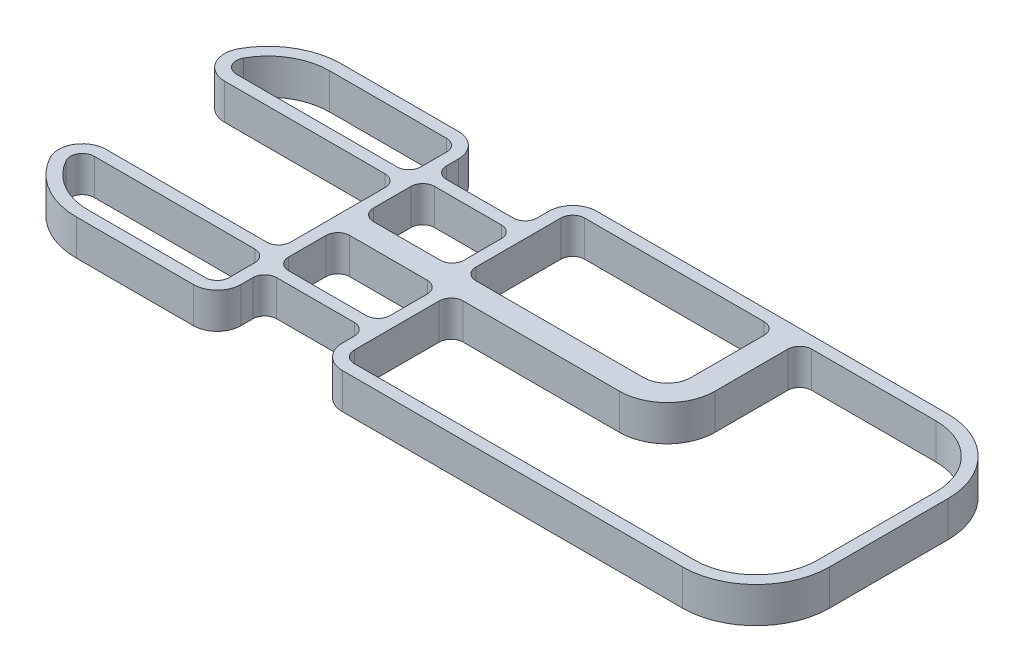
from build123d import *

# Parameters (mm, degrees)
BOSS_EXTRUDE1_DEPTH   = 19.05
BOSS_EXTRUDE1_2_DEPTH = 19.05
SKETCH4_W             = 6.35
SKETCH4_H             = 63.131908364
CUT_EXTRUDE4_DEPTH    = 19.05
BOSS_EXTRUDE2_DEPTH   = 19.05
BOSS_EXTRUDE3_DEPTH   = 19.05
FILLET2_R             = 6.35
FILLET3_R             = 12.7
FILLET4_R             = 12.7
FILLET5_R             = 25.4


with BuildPart() as part:
    # Sketch1 → Boss-Extrude1 (new body)
    with BuildSketch(Plane(origin=(0, 0, 0), x_dir=(1, 0, 0), z_dir=(0, 1, 0))):
        with BuildLine():
            Line((-200.920268311, 32.916976578), (-200.920268311, -30.214931786))
            ThreePointArc((-200.920268311, -30.214931786), (-189.456017676, -57.892081151), (-161.778868311, -69.356331786))
            Line((-161.778868311, -69.356331786), (-86.620268311, -69.356331786))
            Line((-86.620268311, -69.356331786), (-86.620268311, -63.006331786))
            Line((-86.620268311, -63.006331786), (-161.778868311, -63.006331786))
            ThreePointArc((-161.778868311, -63.006331786), (-184.965889616, -53.401953091), (-194.570268311, -30.214931786))
            Line((-194.570268311, -30.214931786), (-194.570268311, 32.916976578))
            ThreePointArc((-194.570268311, 32.916976578), (-184.965889616, 56.103997883), (-161.778868311, 65.708376578))
            Line((-161.778868311, 65.708376578), (-86.620268311, 65.708376578))
            Line((-86.620268311, 65.708376578), (-86.620268311, 72.058376578))
            Line((-86.620268311, 72.058376578), (-161.778868311, 72.058376578))
            ThreePointArc((-161.778868311, 72.058376578), (-189.456017676, 60.594125943), (-200.920268311, 32.916976578))
        make_face()
    extrude(amount=BOSS_EXTRUDE1_DEPTH)

    # Sketch4 → Cut-Extrude4 (cut)
    with BuildSketch(Plane(origin=(0, 19.05, 0), x_dir=(1, 0, 0), z_dir=(0, 1, 0))):
        with Locations((-197.745268311, 1.351022396)):
            Rectangle(SKETCH4_W, SKETCH4_H)
    extrude(amount=-CUT_EXTRUDE4_DEPTH, mode=Mode.SUBTRACT)

    # Sketch5 → Boss-Extrude2 (add)
    with BuildSketch(Plane(origin=(0, 0, 0), x_dir=(1, 0, 0), z_dir=(0, 1, 0))):
        with BuildLine():
            Line((-194.570268311, -30.214931786), (-86.620268311, -30.214931786))
            Line((-86.620268311, -30.214931786), (-86.620268311, -63.006331786))
            Line((-86.620268311, -63.006331786), (-92.970268311, -63.006331786))
            Line((-92.970268311, -63.006331786), (-92.970268311, -36.564931786))
            Line((-92.970268311, -36.564931786), (-193.949560159, -36.564931786))
            ThreePointArc((-193.949560159, -36.564931786), (-194.414722357, -33.405064174), (-194.570268311, -30.214931786))
        make_face()
        with BuildLine():
            Line((-92.970268311, 65.708376578), (-86.620268311, 65.708376578))
            Line((-86.620268311, 65.708376578), (-86.620268311, 32.916976578))
            Line((-86.620268311, 32.916976578), (-194.570268311, 32.916976578))
            ThreePointArc((-194.570268311, 32.916976578), (-194.414722357, 36.107108966), (-193.949560159, 39.266976578))
            Line((-193.949560159, 39.266976578), (-92.970268311, 39.266976578))
            Line((-92.970268311, 39.266976578), (-92.970268311, 65.708376578))
        make_face()
    extrude(amount=BOSS_EXTRUDE2_DEPTH)



with BuildPart() as body_2:
    # Sketch1 → Boss-Extrude1 2 (new body)
    with BuildSketch(Plane(origin=(0, 0, 0), x_dir=(1, 0, 0), z_dir=(0, 1, 0))):
        with BuildLine():
            Line((200.844440053, -30.214931786), (200.844440053, 32.916976578))
            ThreePointArc((200.844440053, 32.916976578), (189.380189418, 60.594125943), (161.703040053, 72.058376578))
            Line((161.703040053, 72.058376578), (-38.360268311, 72.058376578))
            Line((-38.360268311, 72.058376578), (-38.360268311, 65.708376578))
            Line((-38.360268311, 65.708376578), (161.703040053, 65.708376578))
            ThreePointArc((161.703040053, 65.708376578), (184.890061358, 56.103997883), (194.494440053, 32.916976578))
            Line((194.494440053, 32.916976578), (194.494440053, -30.214931786))
            ThreePointArc((194.494440053, -30.214931786), (184.890061358, -53.401953091), (161.703040053, -63.006331786))
            Line((161.703040053, -63.006331786), (-32.518268311, -63.006331786))
            Line((-32.518268311, -63.006331786), (-32.518268311, -69.356331786))
            Line((-32.518268311, -69.356331786), (161.703040053, -69.356331786))
            ThreePointArc((161.703040053, -69.356331786), (189.380189418, -57.892081151), (200.844440053, -30.214931786))
        make_face()
    extrude(amount=BOSS_EXTRUDE1_2_DEPTH)


with BuildPart() as part_1:
    add(part.part)

    add(body_2.part)  # Boss-Extrude3 merges body 2
    # Sketch6 → Boss-Extrude3 (add)
    with BuildSketch(Plane(origin=(0, 0, 0), x_dir=(1, 0, 0), z_dir=(0, 1, 0))):
        Polygon((-86.620268311, -43.956331786), (-32.518268311, -43.956331786), (-32.518268311, -63.006331786), (-26.168268311, -63.006331786), (-26.168268311, -37.606331786), (-26.168268311, -4.998977604), (89.084440053, -4.998977604), (89.084440053, 65.708376578), (76.384440053, 65.708376578), (76.384440053, 7.701022396), (-32.010268311, 7.701022396), (-32.010268311, 40.308376578), (-32.010268311, 65.708376578), (-38.360268311, 65.708376578), (-38.360268311, 46.658376578), (-86.620268311, 46.658376578), (-86.620268311, 40.308376578), (-38.360268311, 40.308376578), (-38.360268311, 7.701022396), (-86.620268311, 7.701022396), (-86.620268311, 32.916976578), (-92.970268311, 32.916976578), (-92.970268311, 7.701022396), (-92.970268311, -4.998977604), (-92.970268311, -30.214931786), (-86.620268311, -30.214931786), (-86.620268311, -4.998977604), (-32.518268311, -4.998977604), (-32.518268311, -37.606331786), (-86.620268311, -37.606331786), align=None)
    extrude(amount=BOSS_EXTRUDE3_DEPTH)

    # Fillet2
    fillet2_edges = [part_1.edges().sort_by_distance(p)[0] for p in [
        (-193.949560159, 9.525, 36.564931786),
        (-92.970268311, 9.525, 36.564931786),
        (-193.949560159, 9.525, -39.266976578),
        (-92.970268311, 9.525, -65.708376578),
        (-92.970268311, 9.525, -39.266976578),
        (-86.620268311, 9.525, 37.606331786),
        (-86.620268311, 9.525, 43.956331786),
        (-32.518268311, 9.525, 43.956331786),
        (-26.168268311, 9.525, 63.006331786),
        (-26.168268311, 9.525, 4.998977604),
        (89.084440053, 9.525, -65.708376578),
        (76.384440053, 9.525, -65.708376578),
        (-32.010268311, 9.525, -7.701022396),
        (-32.010268311, 9.525, -65.708376578),
        (-38.360268311, 9.525, -46.658376578),
        (-86.620268311, 9.525, -46.658376578),
        (-86.620268311, 9.525, -40.308376578),
        (-38.360268311, 9.525, -40.308376578),
        (-38.360268311, 9.525, -7.701022396),
        (-86.620268311, 9.525, -7.701022396),
        (-92.970268311, 9.525, -32.916976578),
        (-92.970268311, 9.525, 30.214931786),
        (-86.620268311, 9.525, 4.998977604),
        (-32.518268311, 9.525, 4.998977604),
        (-32.518268311, 9.525, 37.606331786),
        (-92.970268311, 9.525, 63.006331786),
    ]]
    fillet(fillet2_edges, radius=FILLET2_R)

    # Fillet3
    fillet3_edges = [part_1.edges().sort_by_distance(p)[0] for p in [
        (-200.920268311, 9.525, 30.214931786),
        (-200.920268311, 9.525, -32.916976578),
        (-86.620268311, 9.525, -72.058376578),
        (-32.518268311, 9.525, 69.356331786),
        (-38.360268311, 9.525, -72.058376578),
        (-86.620268311, 9.525, 69.356331786),
    ]]
    fillet(fillet3_edges, radius=FILLET3_R)

    # Fillet4
    fillet4_edges = [part_1.edges().sort_by_distance(p)[0] for p in [
        (76.384440053, 9.525, -7.701022396),
    ]]
    fillet(fillet4_edges, radius=FILLET4_R)

    # Fillet5
    fillet5_edges = [part_1.edges().sort_by_distance(p)[0] for p in [
        (89.084440053, 9.525, 4.998977604),
    ]]
    fillet(fillet5_edges, radius=FILLET5_R)


solid = part_1.part
